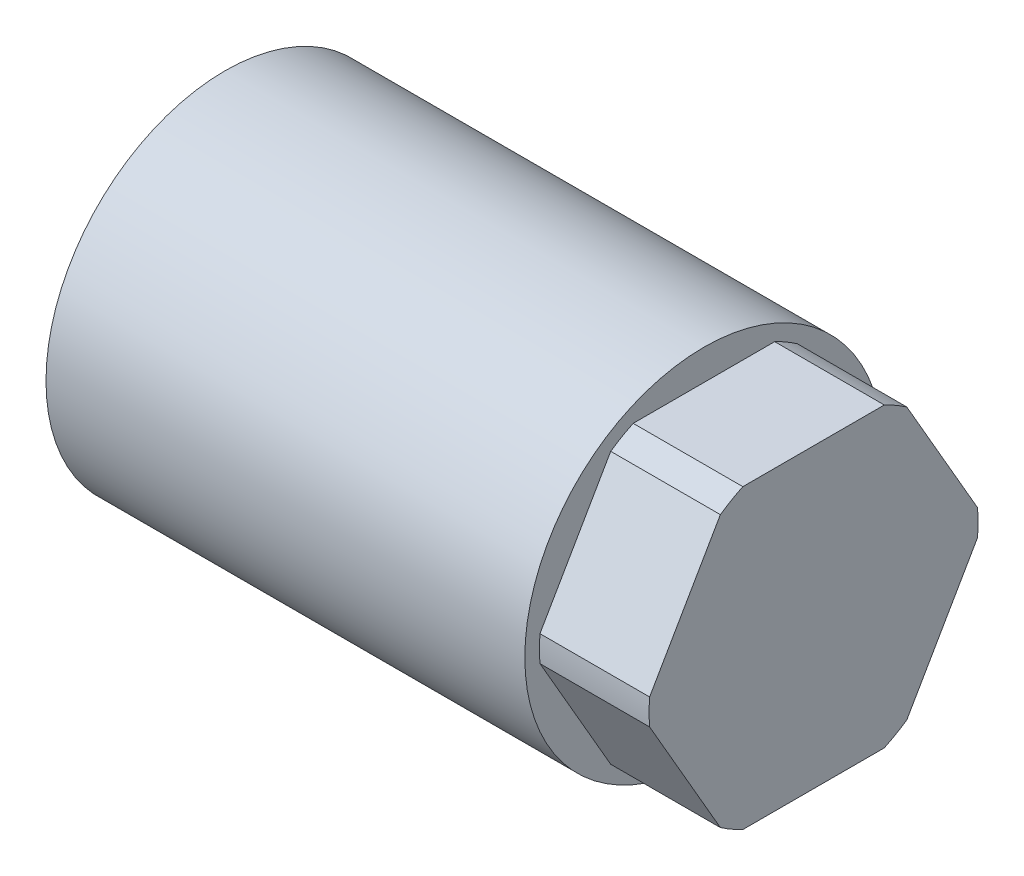
from build123d import *

# Parameters (mm, degrees)
SKETCH3_OUTSIDE_W  = 40.796
SKETCH3_OUTSIDE_H  = 40.796
CUT_EXTRUDE5_DEPTH = 7.62
SKETCH4_R          = 6.35
CUT_EXTRUDE6_DEPTH = 20.05


with BuildPart() as part:
    # Sketch1 → Revolve1 (revolve)
    with BuildSketch(Plane.XY):
        Polygon((0, 11.43), (-7.62, 11.43), (-7.62, 12.446), (-40.894, 12.446), (-40.894, 0), (19.05, 0), (19.05, 6.35), (0, 6.35), align=None)
    revolve(axis=Axis((-40.894, 0, 0), (1, 0, 0)))

    # Sketch3 outside → Cut-Extrude5 (cut)
    with BuildSketch(Plane(origin=(0, 0, 0), x_dir=(0, 0, -1), z_dir=(1, 0, 0))):
        Rectangle(SKETCH3_OUTSIDE_W, SKETCH3_OUTSIDE_H)
        Polygon((5.95753309, 10.31875), (-5.95753309, 10.31875), (-11.91506618, 0), (-5.95753309, -10.31875), (5.95753309, -10.31875), (11.91506618, 0), align=None, mode=Mode.SUBTRACT)
    extrude(amount=-CUT_EXTRUDE5_DEPTH, mode=Mode.SUBTRACT)

    # Sketch4 → Cut-Extrude6 (cut, through all)
    with BuildSketch(Plane(origin=(0, 0, 0), x_dir=(0, 0, -1), z_dir=(1, 0, 0))):
        Circle(SKETCH4_R)
    extrude(amount=CUT_EXTRUDE6_DEPTH, mode=Mode.SUBTRACT)


solid = part.part
